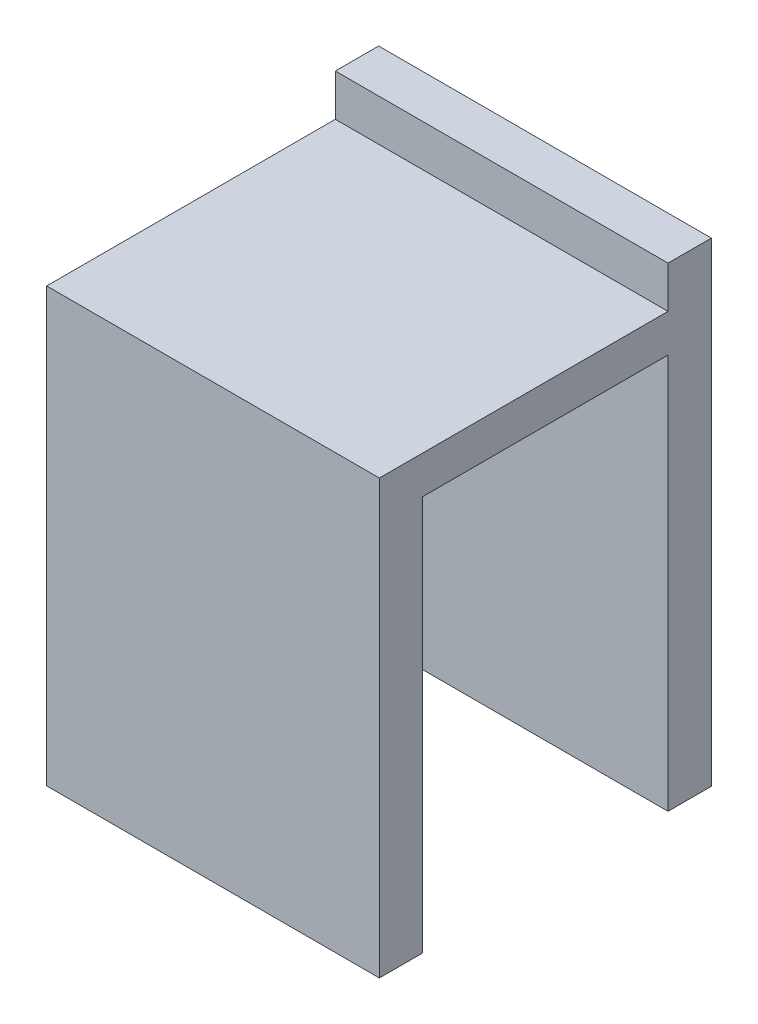
from build123d import *

# Parameters (mm, degrees)
BOSS_EXTRUDE1_DEPTH = 3
SKETCH3_W           = 23.052059357
SKETCH3_H           = 2.618596089
BOSS_EXTRUDE2_DEPTH = 20
SKETCH5_W           = 23.052059357
SKETCH5_H           = 27.381403911
BOSS_EXTRUDE3_DEPTH = 3


with BuildPart() as part:
    # Sketch2 → Boss-Extrude1 (new body)
    with BuildSketch(Plane(origin=(0, 0, -200), x_dir=(-1, 0, 0), z_dir=(0, 0, -1))):
        Polygon((91.240837696, 22.154450262), (91.240837696, -7.845549738), (68.188778339, -7.845549738), (68.188778339, 22.154450262), (68.188778339, 25.05163022), (91.240837696, 25.05163022), align=None)
    extrude(amount=BOSS_EXTRUDE1_DEPTH)

    # Sketch3 → Boss-Extrude2 (add)
    with BuildSketch(Plane.XY.offset(-200)):
        with Locations((-79.714808018, 20.845152218)):
            Rectangle(SKETCH3_W, SKETCH3_H)
    extrude(amount=BOSS_EXTRUDE2_DEPTH)

    # Sketch5 → Boss-Extrude3 (add)
    with BuildSketch(Plane.XY.offset(-180)):
        with Locations((-79.714808018, 5.845152217)):
            Rectangle(SKETCH5_W, SKETCH5_H)
    extrude(amount=-BOSS_EXTRUDE3_DEPTH)


solid = part.part
